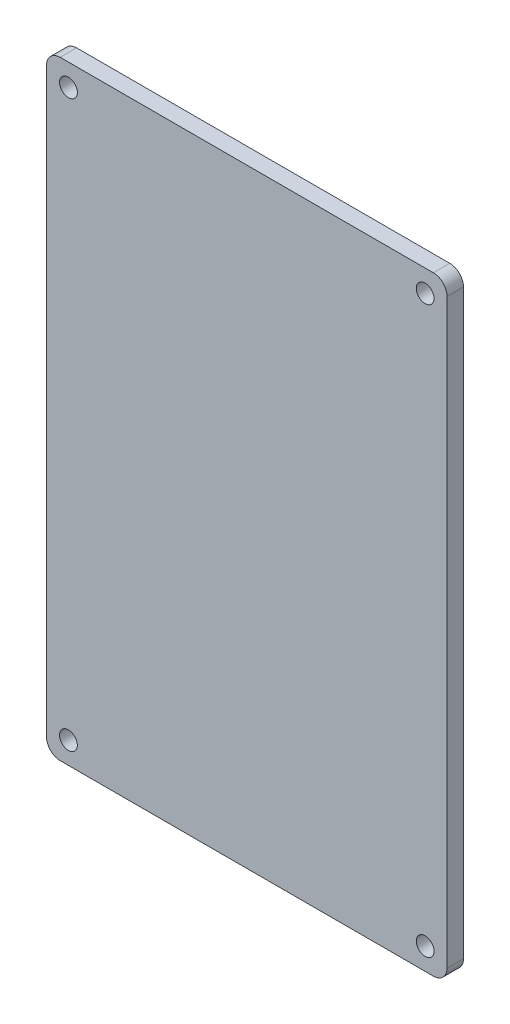
from build123d import *

# Parameters (mm, degrees)
MODEL_R         = 1.625
EXTRUDE_2_DEPTH = 3


with BuildPart() as part:
    # Model → 凸台-拉伸2 (new body)
    with BuildSketch(Plane.XY):
        with BuildLine():
            Line((73.152058773, 8.000078124), (73.152058773, 108.749885124))
            ThreePointArc((73.152058773, 108.749885124), (72.419825726, 110.517652077), (70.652058773, 111.249885124))
            Line((70.652058773, 111.249885124), (8.001843373, 111.249885124))
            Line((8.001843373, 111.249885124), (2.501843373, 111.249885124))
            ThreePointArc((2.501843373, 111.249885124), (0.73407642, 110.517652077), (0.001843373, 108.749885124))
            Line((0.001843373, 108.749885124), (0.001843373, 8.000078124))
            Line((0.001843373, 8.000078124), (0.001843373, 2.500078124))
            ThreePointArc((0.001843373, 2.500078124), (0.73407642, 0.732311171), (2.501843373, 7.8124e-05))
            Line((2.501843373, 7.8124e-05), (65.152058773, 7.8124e-05))
            Line((65.152058773, 7.8124e-05), (70.652058773, 7.8124e-05))
            ThreePointArc((70.652058773, 7.8124e-05), (72.419825726, 0.732311171), (73.152058773, 2.500078124))
            Line((73.152058773, 2.500078124), (73.152058773, 8.000078124))
        make_face()
        with Locations((69.152058773, 107.249885124)):
            Circle(MODEL_R, mode=Mode.SUBTRACT)
        with Locations((4.001843373, 107.249885124)):
            Circle(MODEL_R, mode=Mode.SUBTRACT)
        with Locations((4.001843373, 4.000078124)):
            Circle(MODEL_R, mode=Mode.SUBTRACT)
        with Locations((69.152058773, 4.000078124)):
            Circle(MODEL_R, mode=Mode.SUBTRACT)
    extrude(amount=EXTRUDE_2_DEPTH)


solid = part.part
